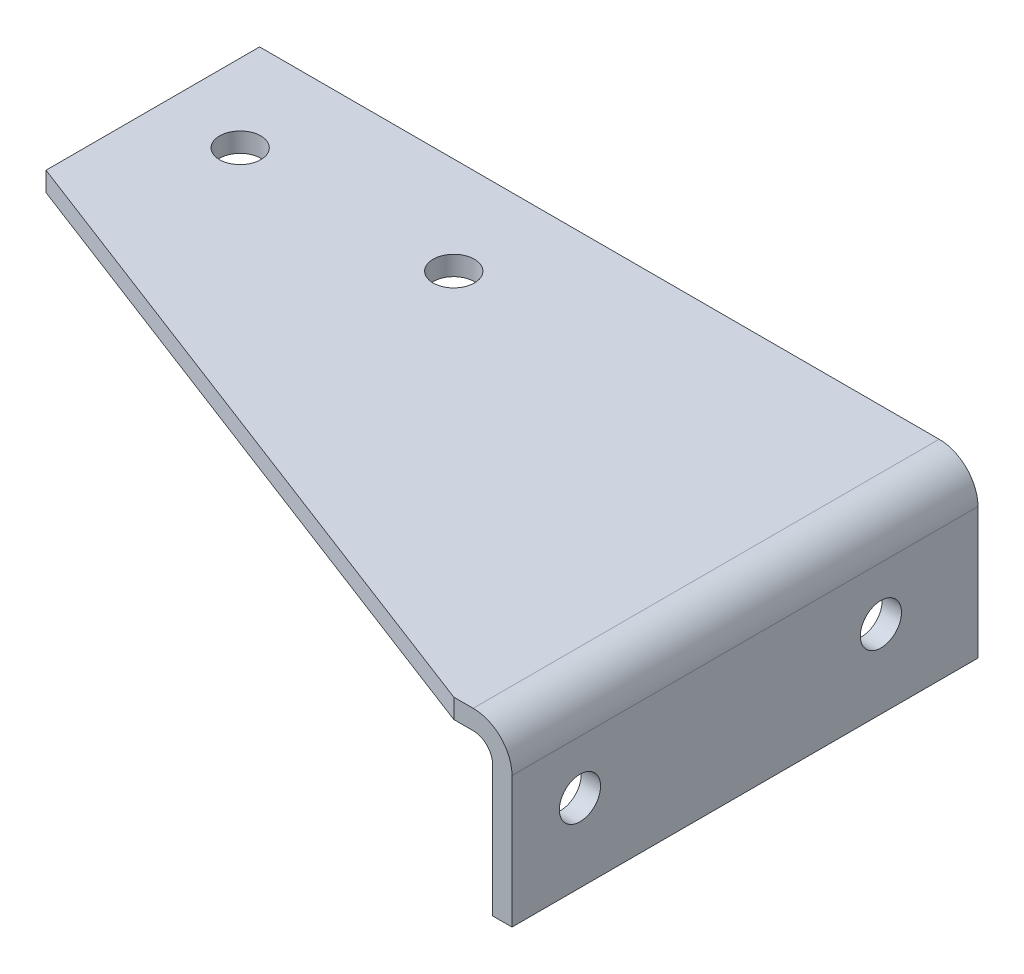
from build123d import *

# Parameters (mm, degrees)
BASE_EXTRUDE_THIN_DEPTH = 152.4
CUT_CNR_DEPTH           = 7.35
CUT_CNR_DEPTH_BACK      = 50.276
HOLE_FLG_D              = 13.462
HOLE_TOP_D              = 13.49375
HOLE_TOP_DEPTH          = 25.4


with BuildPart() as part:
    # Sketch1 → Base-Extrude-Thin (new body)
    with BuildSketch(Plane.XY):
        with BuildLine():
            Line((-228.6, 0), (-6.35, 0))
            ThreePointArc((-6.35, 0), (-1.859871939, -1.859871939), (0, -6.35))
            Line((0, -6.35), (0, -49.276))
            Line((0, -49.276), (6.35, -49.276))
            Line((6.35, -49.276), (6.35, -6.35))
            ThreePointArc((6.35, -6.35), (2.630256121, 2.630256121), (-6.35, 6.35))
            Line((-6.35, 6.35), (-228.6, 6.35))
            Line((-228.6, 6.35), (-228.6, 0))
        make_face()
    extrude(amount=BASE_EXTRUDE_THIN_DEPTH)

    # Sketch2 → Cut cnr (cut, two sides)
    with BuildSketch(Plane(origin=(0, 0, 0), x_dir=(1, 0, 0), z_dir=(0, 1, 0))) as cut_cnr_sk:
        Polygon((-731.624052823, 122.482726079), (-228.6, -69.85), (-12.7, -152.4), (490.324052823, -344.732726079), (105.658600664, -1350.780831726), (-1116.289504982, -883.565379567), align=None)
    extrude(amount=CUT_CNR_DEPTH, mode=Mode.SUBTRACT)
    extrude(cut_cnr_sk.sketch, amount=-CUT_CNR_DEPTH_BACK, mode=Mode.SUBTRACT)

    # Hole-flg (through all)
    with Locations(Plane(origin=(6.35, 0, 0), x_dir=(0, 0, -1), z_dir=(1, 0, 0))):
        with Locations((-130.175, -23.8125), (-31.75, -23.8125)):
            Hole(HOLE_FLG_D / 2)

    # Hole-top
    with Locations(Plane(origin=(0, 6.35, 0), x_dir=(-1, 0, 0), z_dir=(0, 1, 0))):
        with Locations((203.2, 31.75), (133.35, 31.75)):
            Hole(HOLE_TOP_D / 2, depth=HOLE_TOP_DEPTH)


solid = part.part
